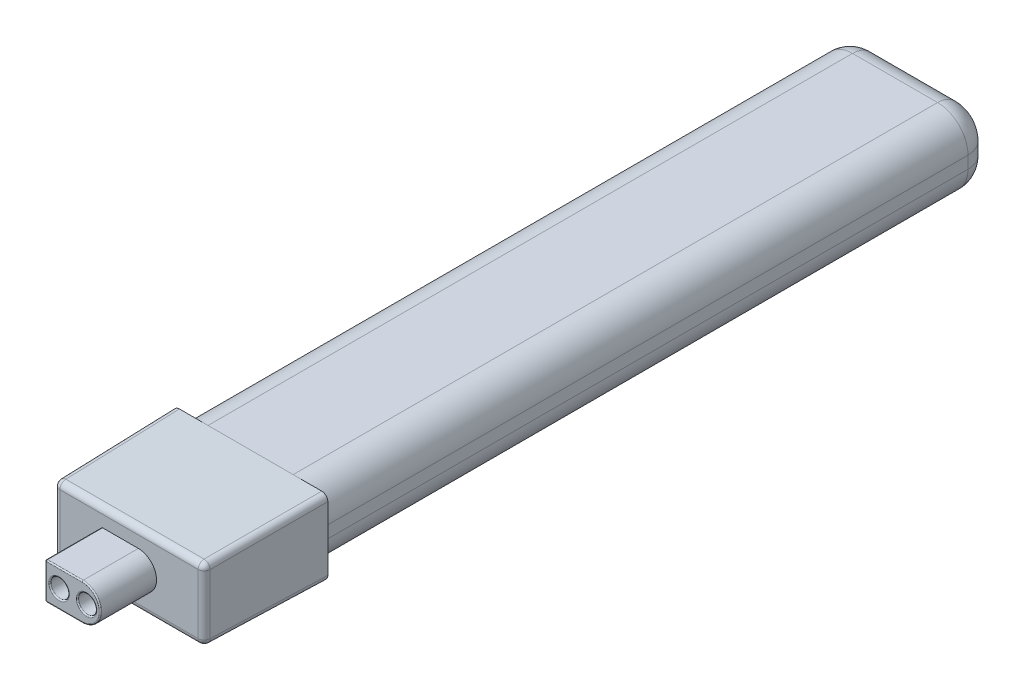
from build123d import *

# Parameters (mm, degrees)
BOSS_EXTRUDE1_DEPTH = 27.5
SKETCH2_W           = 12.7
SKETCH2_H           = 6.25
BOSS_EXTRUDE2_DEPTH = 10
BOSS_EXTRUDE2_TAPER = 1
FILLET2_R           = 2
SKETCH4_R           = 0.75
BOSS_EXTRUDE4_DEPTH = 4.62
FILLET3_R           = 0.5
FILLET4_R           = 0.1


with BuildPart() as part:
    # Sketch1 → Boss-Extrude1 (new body, symmetric)
    with BuildSketch(Plane.XY):
        with BuildLine():
            Line((-3.5, -3), (3.5, -3))
            ThreePointArc((3.5, -3), (5.267766953, -2.267766953), (6, -0.5))
            Line((6, -0.5), (6, 0.5))
            ThreePointArc((6, 0.5), (5.267766953, 2.267766953), (3.5, 3))
            Line((3.5, 3), (-3.5, 3))
            ThreePointArc((-3.5, 3), (-5.267766953, 2.267766953), (-6, 0.5))
            Line((-6, 0.5), (-6, -0.5))
            ThreePointArc((-6, -0.5), (-5.267766953, -2.267766953), (-3.5, -3))
        make_face()
    extrude(amount=BOSS_EXTRUDE1_DEPTH, both=True)

    # Sketch2 → Boss-Extrude2 (add)
    with BuildSketch(Plane.XY.offset(27.5)):
        with Locations((0, -0.125)):
            Rectangle(SKETCH2_W, SKETCH2_H)
    extrude(amount=BOSS_EXTRUDE2_DEPTH, taper=BOSS_EXTRUDE2_TAPER)

    # Fillet2
    fillet2_edges = [part.edges().sort_by_distance(p)[0] for p in [
        (6, 0, -27.5),
        (5.267766953, -2.267766953, -27.5),
        (0, -3, -27.5),
        (-5.267766953, -2.267766953, -27.5),
        (-6, 0, -27.5),
        (-5.267766953, 2.267766953, -27.5),
        (0, 3, -27.5),
        (5.267766953, 2.267766953, -27.5),
    ]]
    fillet(fillet2_edges, radius=FILLET2_R)

    # Sketch4 → Boss-Extrude4 (add)
    with BuildSketch(Plane.XY.offset(37.5)):
        with BuildLine():
            Line((-2.265, 1.375), (0.765, 1.375))
            ThreePointArc((0.765, 1.375), (2.265, -0.125), (0.765, -1.625))
            Line((0.765, -1.625), (-2.265, -1.625))
            Line((-2.265, -1.625), (-2.265, 1.375))
        make_face()
        with Locations((-1.1325, -0.125)):
            Circle(SKETCH4_R, mode=Mode.SUBTRACT)
        with Locations((1.1325, -0.125)):
            Circle(SKETCH4_R, mode=Mode.SUBTRACT)
    extrude(amount=BOSS_EXTRUDE4_DEPTH)

    # Fillet3
    fillet3_edges = [part.edges().sort_by_distance(p)[0] for p in [
        (6.262724675, -3.162724675, 32.5),
        (6.262724675, 2.912724675, 32.5),
        (-6.262724675, 2.912724675, 32.5),
        (-6.262724213, -3.162724213, 32.500026465),
        (6.175449351, -0.125, 37.5),
        (0, 2.825449351, 37.5),
        (-6.175449351, -0.125, 37.5),
        (0, -3.075449351, 37.5),
    ]]
    fillet(fillet3_edges, radius=FILLET3_R)

    # Fillet4
    fillet4_edges = [part.edges().sort_by_distance(p)[0] for p in [
        (-2.265, -0.125, 42.12),
        (-0.75, -1.625, 42.12),
        (2.265, -0.125, 42.12),
        (-0.75, 1.375, 42.12),
        (-2.265, 1.375, 39.81),
        (-2.265, -1.625, 39.81),
        (-1.8825, -0.125, 42.12),
        (0.3825, -0.125, 42.12),
    ]]
    fillet(fillet4_edges, radius=FILLET4_R)


solid = part.part
